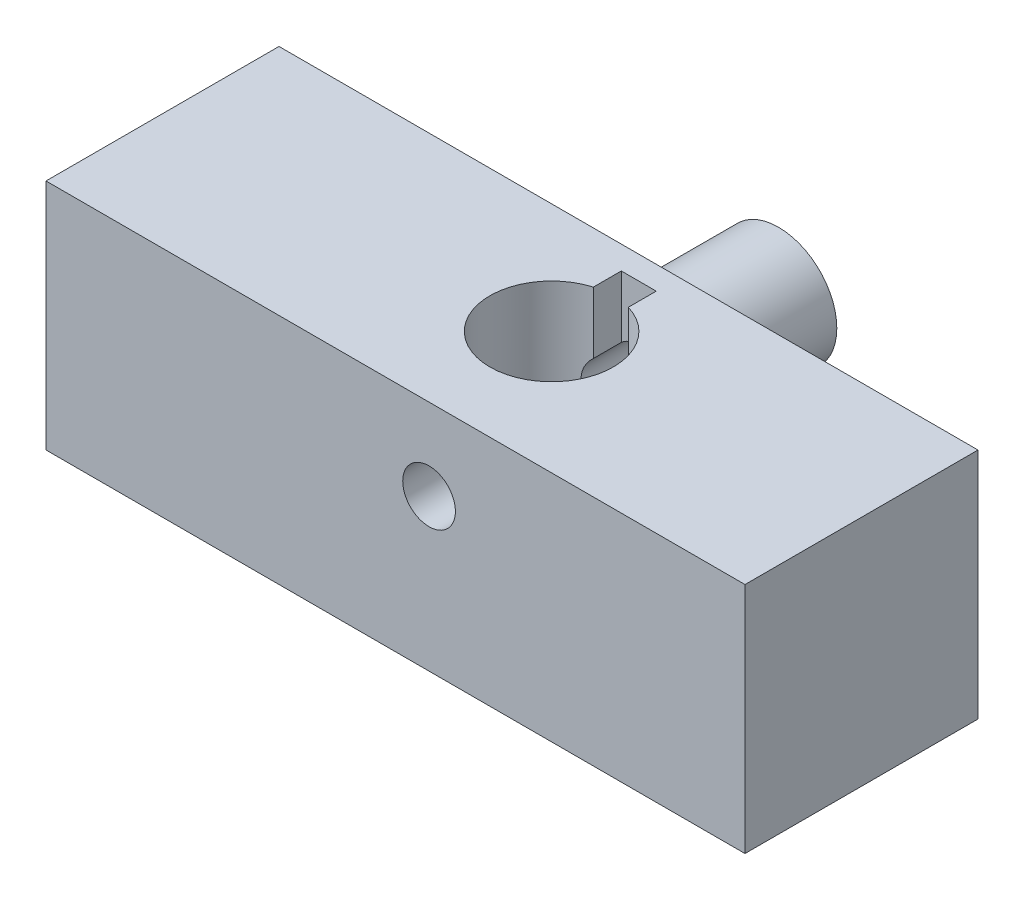
from build123d import *

# Parameters (mm, degrees)
SKETCH1_W                = 30
SKETCH1_H                = 10
BOSS_EXTRUDE1_DEPTH      = 10
SKETCH2_R                = 2.5
SKETCH2_R_2              = 1.1303
F_4_40_SCREW_SPACE_DEPTH = 5
SKETCH5_R                = 1.1303
CUT_EXTRUDE3_DEPTH       = 16
SKETCH3_R                = 2.65
CUT_EXTRUDE1_DEPTH       = 8
SKETCH4_W                = 1.5
SKETCH4_H                = 1.778161356
CUT_EXTRUDE2_DEPTH       = 5


with BuildPart() as part:
    # Sketch1 → Boss-Extrude1 (new body)
    with BuildSketch(Plane.XY):
        with Locations((-1.440677966, 0.809495308)):
            Rectangle(SKETCH1_W, SKETCH1_H)
    extrude(amount=BOSS_EXTRUDE1_DEPTH)

    # Sketch2 → 4-40 screw space (add)
    with BuildSketch(Plane(origin=(0, 0, 0), x_dir=(-1, 0, 0), z_dir=(0, 0, -1))):
        with Locations((0, 2.309495308)):
            Circle(SKETCH2_R)
        with Locations((0, 2.309495308)):
            Circle(SKETCH2_R_2, mode=Mode.SUBTRACT)
    extrude(amount=F_4_40_SCREW_SPACE_DEPTH)

    # Sketch5 → Cut-Extrude3 (cut, through all)
    with BuildSketch(Plane(origin=(0, 0, -5), x_dir=(-1, 0, 0), z_dir=(0, 0, -1))):
        with Locations((0, 2.309495308)):
            Circle(SKETCH5_R)
    extrude(amount=-CUT_EXTRUDE3_DEPTH, mode=Mode.SUBTRACT)

    # Sketch3 → Cut-Extrude1 (cut)
    with BuildSketch(Plane(origin=(0, 5.809495308, 0), x_dir=(1, 0, 0), z_dir=(0, 1, 0))):
        with Locations((0, -4.740342164)):
            Circle(SKETCH3_R)
    extrude(amount=-CUT_EXTRUDE1_DEPTH, mode=Mode.SUBTRACT)

    # Sketch4 → Cut-Extrude2 (cut)
    with BuildSketch(Plane(origin=(0, 5.809495308, 0), x_dir=(1, 0, 0), z_dir=(0, 1, 0))):
        with Locations((0, -1.889080678)):
            Rectangle(SKETCH4_W, SKETCH4_H)
    extrude(amount=-CUT_EXTRUDE2_DEPTH, mode=Mode.SUBTRACT)


solid = part.part
